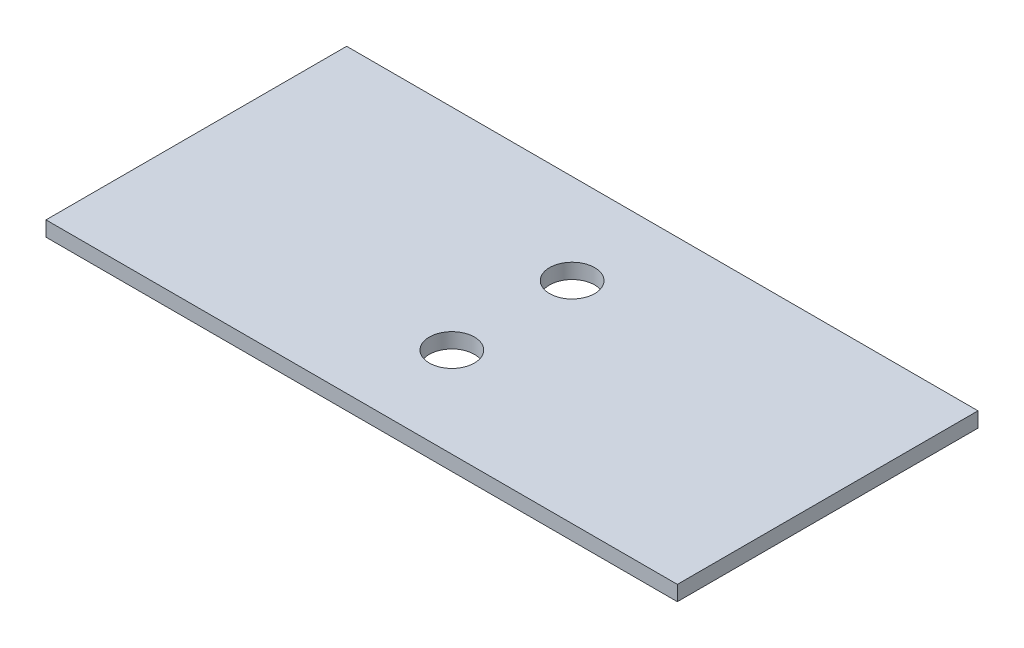
from build123d import *

# Parameters (mm, degrees)
SKETCH_1_W      = 42
SKETCH_1_H      = 20
SKETCH_1_R      = 1.5
EXTRUDE_1_DEPTH = 1


with BuildPart() as part:
    # Эскиз1 → Бобышка-Вытянуть1 (new body)
    with BuildSketch(Plane(origin=(0, 0, 0), x_dir=(1, 0, 0), z_dir=(0, 1, 0))):
        with Locations((21, 10)):
            Rectangle(SKETCH_1_W, SKETCH_1_H)
        with Locations((21, 14)):
            Circle(SKETCH_1_R, mode=Mode.SUBTRACT)
        with Locations((21, 6)):
            Circle(SKETCH_1_R, mode=Mode.SUBTRACT)
    extrude(amount=EXTRUDE_1_DEPTH)


solid = part.part
